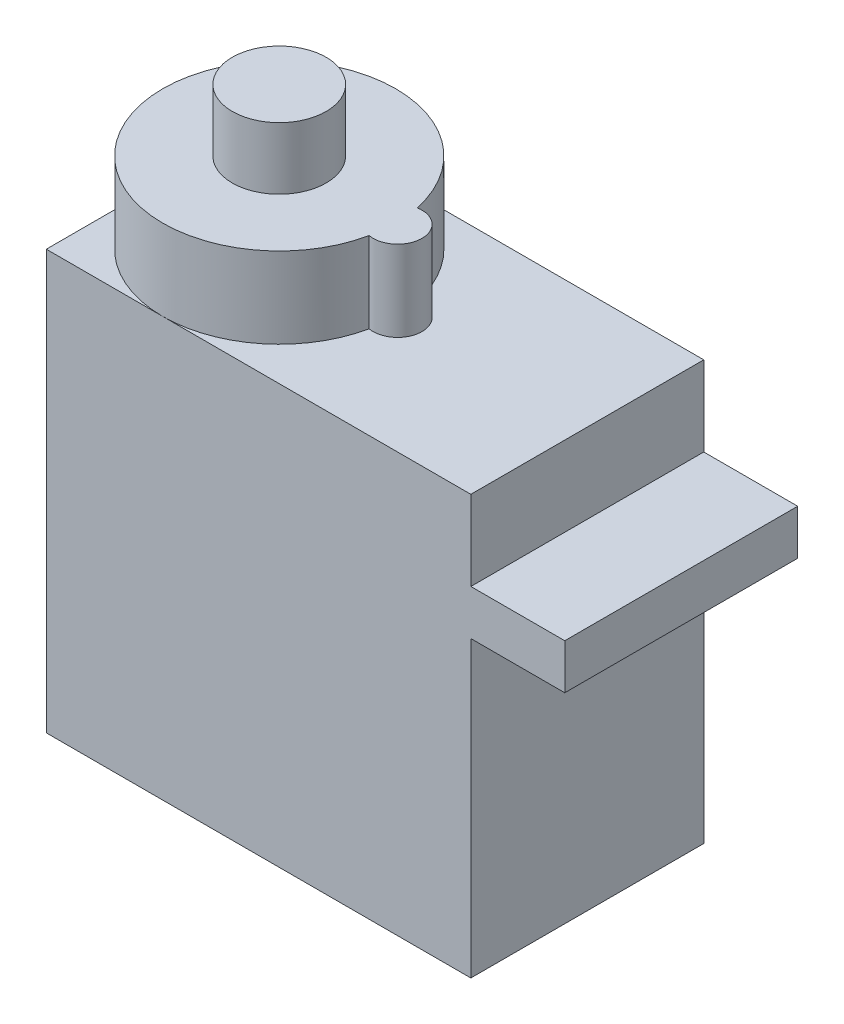
from build123d import *

# Parameters (mm, degrees)
SKETCH1_W           = 22.6
SKETCH1_H           = 12.4
BOSS_EXTRUDE1_DEPTH = 22.3
SKETCH2_W           = 12.4
SKETCH2_H           = 2.4
BOSS_EXTRUDE2_DEPTH = 5
BOSS_EXTRUDE4_DEPTH = 4.3
SKETCH7_R           = 2.5
BOSS_EXTRUDE5_DEPTH = 3.3


with BuildPart() as part:
    # Sketch1 → Boss-Extrude1 (new body)
    with BuildSketch(Plane(origin=(0, 0, 0), x_dir=(1, 0, 0), z_dir=(0, 1, 0))):
        Rectangle(SKETCH1_W, SKETCH1_H)
    extrude(amount=BOSS_EXTRUDE1_DEPTH)

    # Sketch2 → Boss-Extrude2 (add)
    with BuildSketch(Plane(origin=(11.3, 0, 0), x_dir=(0, 0, -1), z_dir=(1, 0, 0))):
        with Locations((0, 16.85)):
            Rectangle(SKETCH2_W, SKETCH2_H)
    extrude(amount=BOSS_EXTRUDE2_DEPTH)

    # Sketch6 → Boss-Extrude4 (add)
    with BuildSketch(Plane(origin=(0, 22.3, 0), x_dir=(1, 0, 0), z_dir=(0, 1, 0))):
        with BuildLine():
            ThreePointArc((0.966666667, -1.278888406), (2.5, 0), (0.966666667, 1.278888406))
            ThreePointArc((0.966666667, 1.278888406), (-11.3, 0), (0.966666667, -1.278888406))
        make_face()
    extrude(amount=BOSS_EXTRUDE4_DEPTH)

    # Sketch7 → Boss-Extrude5 (add)
    with BuildSketch(Plane(origin=(0, 26.6, 0), x_dir=(1, 0, 0), z_dir=(0, 1, 0))):
        with Locations((-5.1, 0)):
            Circle(SKETCH7_R)
    extrude(amount=BOSS_EXTRUDE5_DEPTH)


solid = part.part
